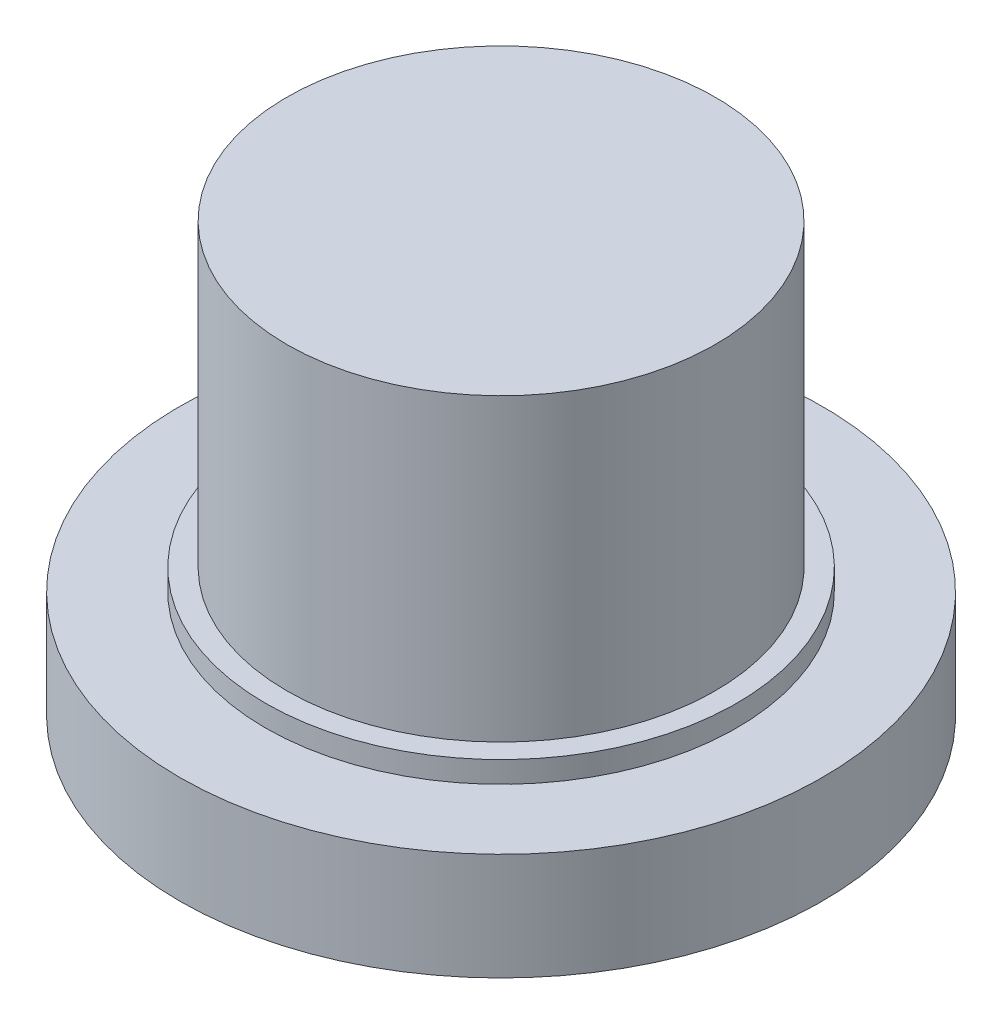
from build123d import *

# Parameters (mm, degrees)
SKETCH1_R           = 15
BOSS_EXTRUDE1_DEPTH = 5
SKETCH2_R           = 10
BOSS_EXTRUDE2_DEPTH = 15
SKETCH3_R           = 7.5
CUT_EXTRUDE1_DEPTH  = 19
SKETCH5_R           = 11
BOSS_EXTRUDE3_DEPTH = 1


with BuildPart() as part:
    # Sketch1 → Boss-Extrude1 (new body)
    with BuildSketch(Plane(origin=(0, 0, 0), x_dir=(1, 0, 0), z_dir=(0, 1, 0))):
        Circle(SKETCH1_R)
    extrude(amount=BOSS_EXTRUDE1_DEPTH)

    # Sketch2 → Boss-Extrude2 (add)
    with BuildSketch(Plane(origin=(0, 5, 0), x_dir=(1, 0, 0), z_dir=(0, 1, 0))):
        Circle(SKETCH2_R)
    extrude(amount=BOSS_EXTRUDE2_DEPTH)

    # Sketch3 → Cut-Extrude1 (cut)
    with BuildSketch(Plane.XZ):
        Circle(SKETCH3_R)
    extrude(amount=-CUT_EXTRUDE1_DEPTH, mode=Mode.SUBTRACT)

    # Sketch5 → Boss-Extrude3 (add)
    with BuildSketch(Plane(origin=(0, 5, 0), x_dir=(1, 0, 0), z_dir=(0, 1, 0))):
        Circle(SKETCH5_R)
    extrude(amount=BOSS_EXTRUDE3_DEPTH)


solid = part.part
